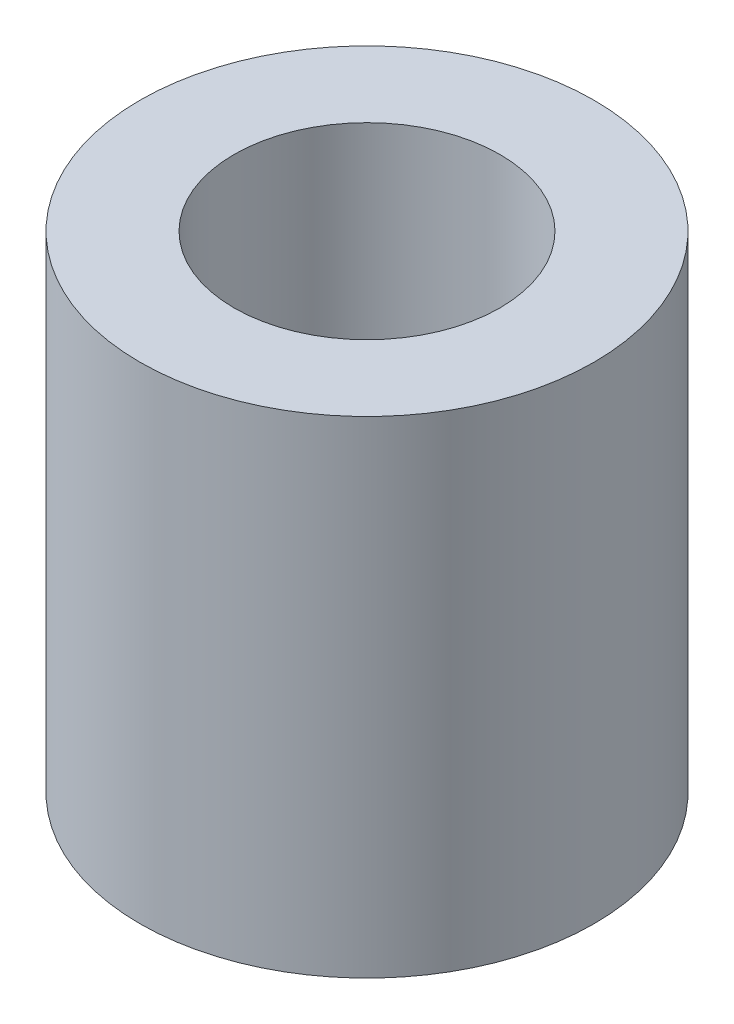
from build123d import *

# Parameters (mm, degrees)
SKETCH1_R           = 7
BOSS_EXTRUDE3_DEPTH = 15
SKETCH4_R           = 4.1
CUT_EXTRUDE1_DEPTH  = 16
SKETCH5_R           = 6.1
CUT_EXTRUDE2_DEPTH  = 3


with BuildPart() as part:
    # Sketch1 → Boss-Extrude3 (new body)
    with BuildSketch(Plane(origin=(0, 0, 0), x_dir=(1, 0, 0), z_dir=(0, 1, 0))):
        with Locations(Location((0, 0, 0), (0, 0, 270))):  # turned: the seam where the file's is
            Circle(SKETCH1_R)
    extrude(amount=BOSS_EXTRUDE3_DEPTH)

    # Sketch4 → Cut-Extrude1 (cut, through all)
    with BuildSketch(Plane(origin=(0, 15, 0), x_dir=(1, 0, 0), z_dir=(0, 1, 0))):
        with Locations(Location((0, 0, 0), (0, 0, 270))):  # turned: the seam where the file's is
            Circle(SKETCH4_R)
    extrude(amount=-CUT_EXTRUDE1_DEPTH, mode=Mode.SUBTRACT)

    # Sketch5 → Cut-Extrude2 (cut)
    with BuildSketch(Plane.XZ):
        with Locations(Location((0, 0, 0), (0, 0, 270))):  # turned: the seam where the file's is
            Circle(SKETCH5_R)
    extrude(amount=-CUT_EXTRUDE2_DEPTH, mode=Mode.SUBTRACT)


solid = part.part
